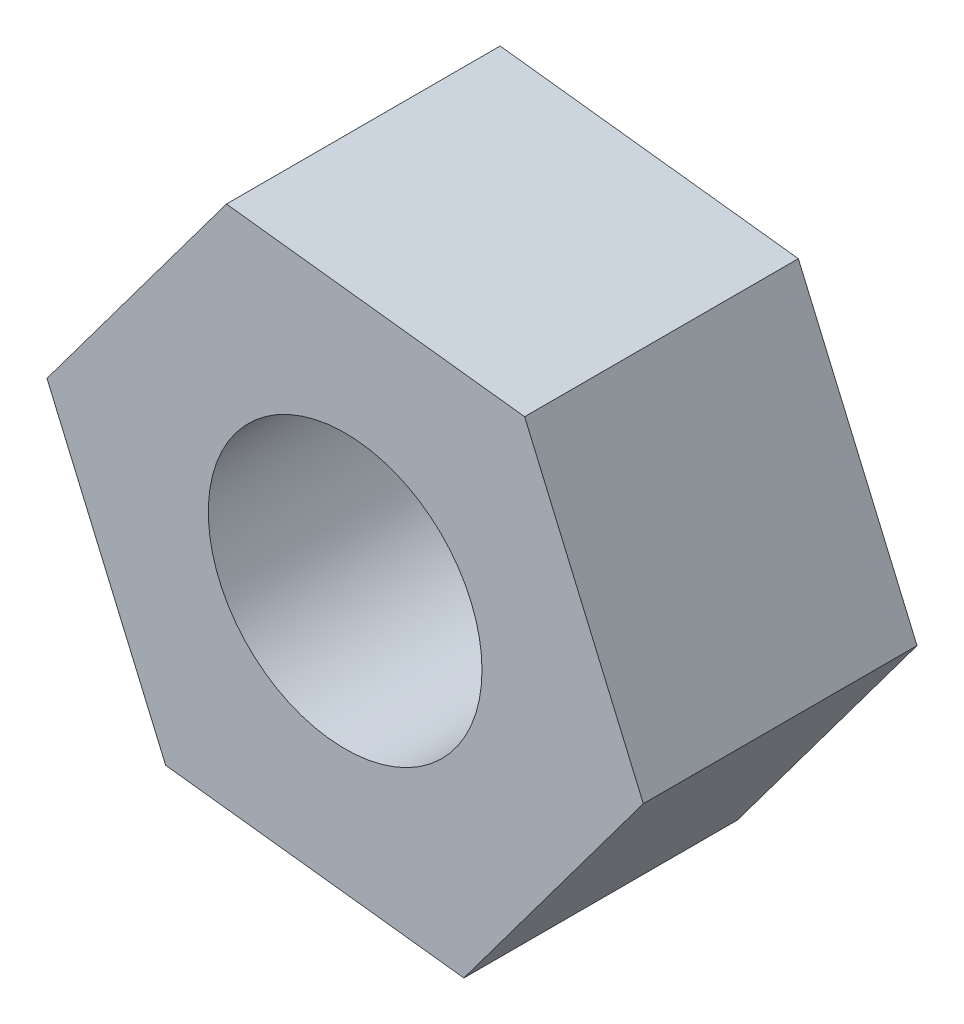
from build123d import *

# Parameters (mm, degrees)
SKETCH_1_R      = 1
EXTRUDE_1_DEPTH = 2


with BuildPart() as part:
    # 草图1 → 凸台-拉伸1 (new body)
    with BuildSketch(Plane.XY):
        Polygon((-18.81869197, -18.732717674), (-20.997597742, -18.476391775), (-22.309035369, -20.235216577), (-21.441567223, -22.250367278), (-19.26266145, -22.506693178), (-17.951223824, -20.747868375), align=None)
        with Locations((-20.130129596, -20.491542476)):
            Circle(SKETCH_1_R, mode=Mode.SUBTRACT)
    extrude(amount=EXTRUDE_1_DEPTH)


solid = part.part
